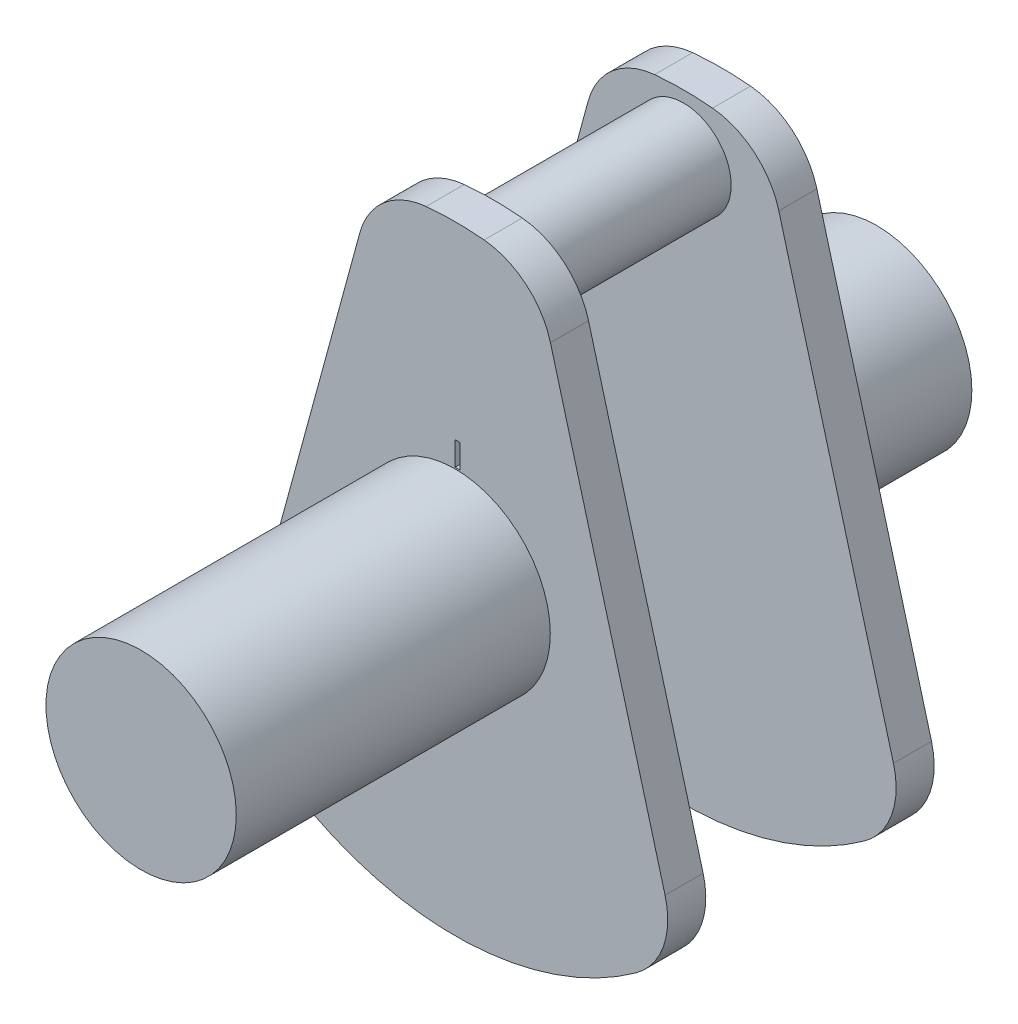
from build123d import *

# Parameters (mm, degrees)
BOSS_EXTRUDE1_DEPTH = 0.8
SKETCH3_R           = 1
BOSS_EXTRUDE2_DEPTH = 2
SKETCH4_R           = 2
BOSS_EXTRUDE3_DEPTH = 3.26
SKETCH5_R           = 2
BOSS_EXTRUDE4_DEPTH = 3.34
SKETCH6_W           = 0.1
SKETCH6_H           = 0.5
CUT_EXTRUDE1_DEPTH  = 0.1


with BuildPart() as part:
    # Sketch2 → Boss-Extrude1 (new body)
    with BuildSketch(Plane.XY):
        with BuildLine():
            Line((-2.002843202, 5.298630925), (-4.411867861, -3.552786589))
            ThreePointArc((-4.411867861, -3.552786589), (-4.376483825, -4.506396112), (-3.804522508, -5.270256966))
            ThreePointArc((-3.804522508, -5.270256966), (0, -6.5), (3.804522508, -5.270256966))
            ThreePointArc((3.804522508, -5.270256966), (4.376483825, -4.506396112), (4.411867861, -3.552786589))
            Line((4.411867861, -3.552786589), (2.002843202, 5.298630925))
            ThreePointArc((2.002843202, 5.298630925), (1.489063424, 6.102778606), (0.608877551, 6.471419329))
            ThreePointArc((0.608877551, 6.471419329), (0, 6.5), (-0.608877551, 6.471419329))
            ThreePointArc((-0.608877551, 6.471419329), (-1.489063424, 6.102778606), (-2.002843202, 5.298630925))
        make_face()
    extrude(amount=BOSS_EXTRUDE1_DEPTH)

    # Sketch3 → Boss-Extrude2 (add)
    with BuildSketch(Plane.XY.offset(0.8)):
        with Locations((0, 5.26)):
            Circle(SKETCH3_R)
    extrude(amount=BOSS_EXTRUDE2_DEPTH)

    # Sketch4 → Boss-Extrude3 (add)
    with BuildSketch(Plane(origin=(0, 0, 0), x_dir=(-1, 0, 0), z_dir=(0, 0, -1))):
        Circle(SKETCH4_R)
    extrude(amount=BOSS_EXTRUDE3_DEPTH)

    # Mirror1: part across plane


with BuildPart() as part_1:
    add(part.part)
    add(part.part.mirror(Plane(origin=(0, 5.26, 2.8), x_dir=(1, 0, 0), z_dir=(0, 0, 1))))

    # Sketch5 → Boss-Extrude4 (add)
    with BuildSketch(Plane.XY.offset(8.86)):
        Circle(SKETCH5_R)
    extrude(amount=BOSS_EXTRUDE4_DEPTH)

    # Sketch6 → Cut-Extrude1 (cut)
    with BuildSketch(Plane.XY.offset(5.6)):
        with Locations((0.05, 2.280573289)):
            Rectangle(SKETCH6_W, SKETCH6_H)
    extrude(amount=-CUT_EXTRUDE1_DEPTH, mode=Mode.SUBTRACT)


solid = part_1.part
